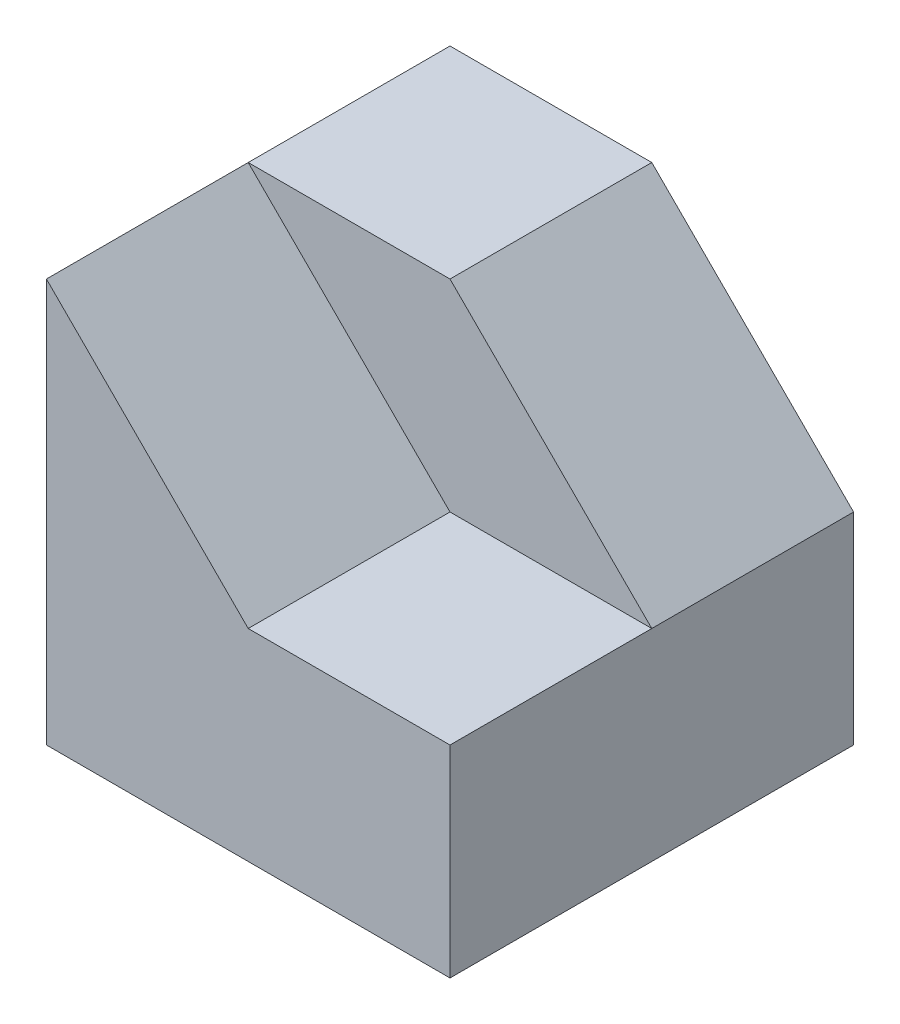
from build123d import *

# Parameters (mm, degrees)
CROQUIS1_W              = 60
CROQUIS1_H              = 60
SALIENTE_EXTRUIR1_DEPTH = 60
CROQUIS2_W              = 30
CROQUIS2_H              = 30
CORTAR_EXTRUIR1_DEPTH   = 30
CORTAR_EXTRUIR2_DEPTH   = 30
CORTAR_EXTRUIR3_DEPTH   = 30


with BuildPart() as part:
    # Croquis1 → Saliente-Extruir1 (new body)
    with BuildSketch(Plane(origin=(0, 0, 0), x_dir=(1, 0, 0), z_dir=(0, 1, 0))):
        with Locations((30, -30)):
            Rectangle(CROQUIS1_W, CROQUIS1_H)
    extrude(amount=SALIENTE_EXTRUIR1_DEPTH)

    # Croquis2 → Cortar-Extruir1 (cut)
    with BuildSketch(Plane(origin=(0, 60, 0), x_dir=(1, 0, 0), z_dir=(0, 1, 0))):
        with Locations((45, -45)):
            Rectangle(CROQUIS2_W, CROQUIS2_H)
    extrude(amount=-CORTAR_EXTRUIR1_DEPTH, mode=Mode.SUBTRACT)

    # Croquis3 → Cortar-Extruir2 (cut)
    with BuildSketch(Plane.XY.offset(30)):
        Polygon((30, 60), (60, 30), (60, 60), align=None)
    extrude(amount=-CORTAR_EXTRUIR2_DEPTH, mode=Mode.SUBTRACT)

    # Croquis4 → Cortar-Extruir3 (cut)
    with BuildSketch(Plane.XY.offset(60)):
        Polygon((0, 60), (30, 30), (30, 60), align=None)
    extrude(amount=-CORTAR_EXTRUIR3_DEPTH, mode=Mode.SUBTRACT)


solid = part.part
